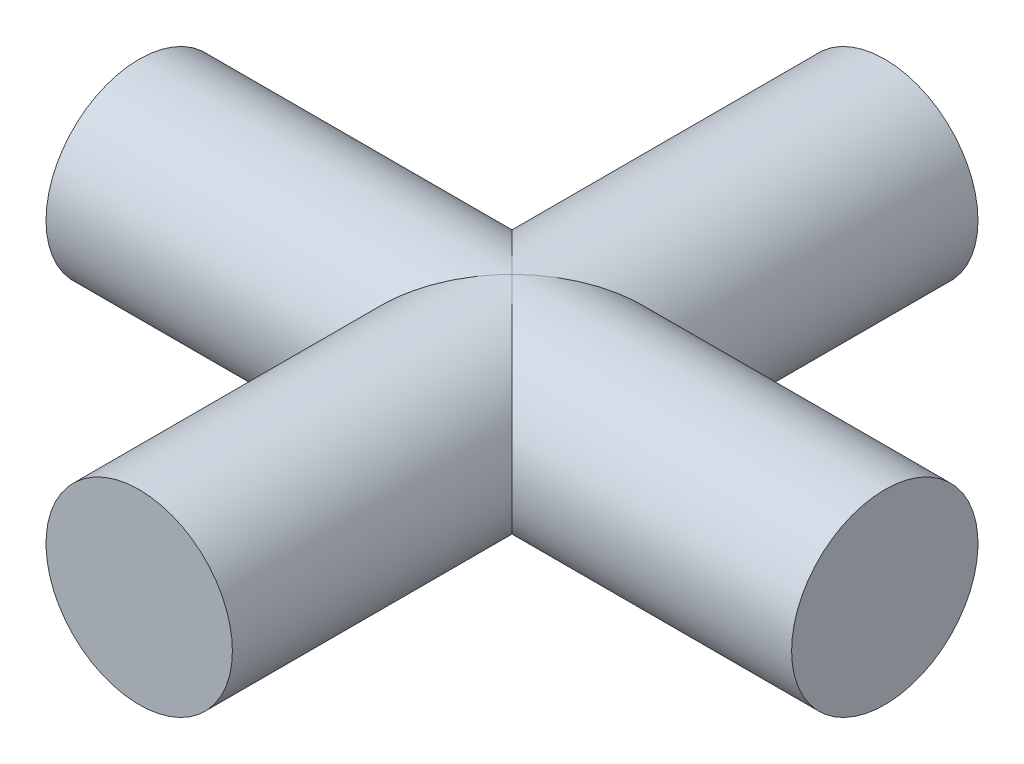
from build123d import *

# Parameters (mm, degrees)
SKETCH1_R           = 6.35
BOSS_EXTRUDE1_DEPTH = 50.8
CIRPATTERN1_COUNT   = 2
CIRPATTERN1_ANGLE   = 90


with BuildPart() as part:
    # Sketch1 → Boss-Extrude1 (new body)
    with BuildSketch(Plane.XY):
        Circle(SKETCH1_R)
    boss_extrude1 = extrude(amount=BOSS_EXTRUDE1_DEPTH)

    # CirPattern1: Boss-Extrude1 ×2 about axis
    cirpattern1_axis = Axis((0, 6.35, 25.4), (0, -1, 0))
    for i in range(1, CIRPATTERN1_COUNT):
        add(boss_extrude1.rotate(cirpattern1_axis, i * CIRPATTERN1_ANGLE / (CIRPATTERN1_COUNT - 1)))


solid = part.part
